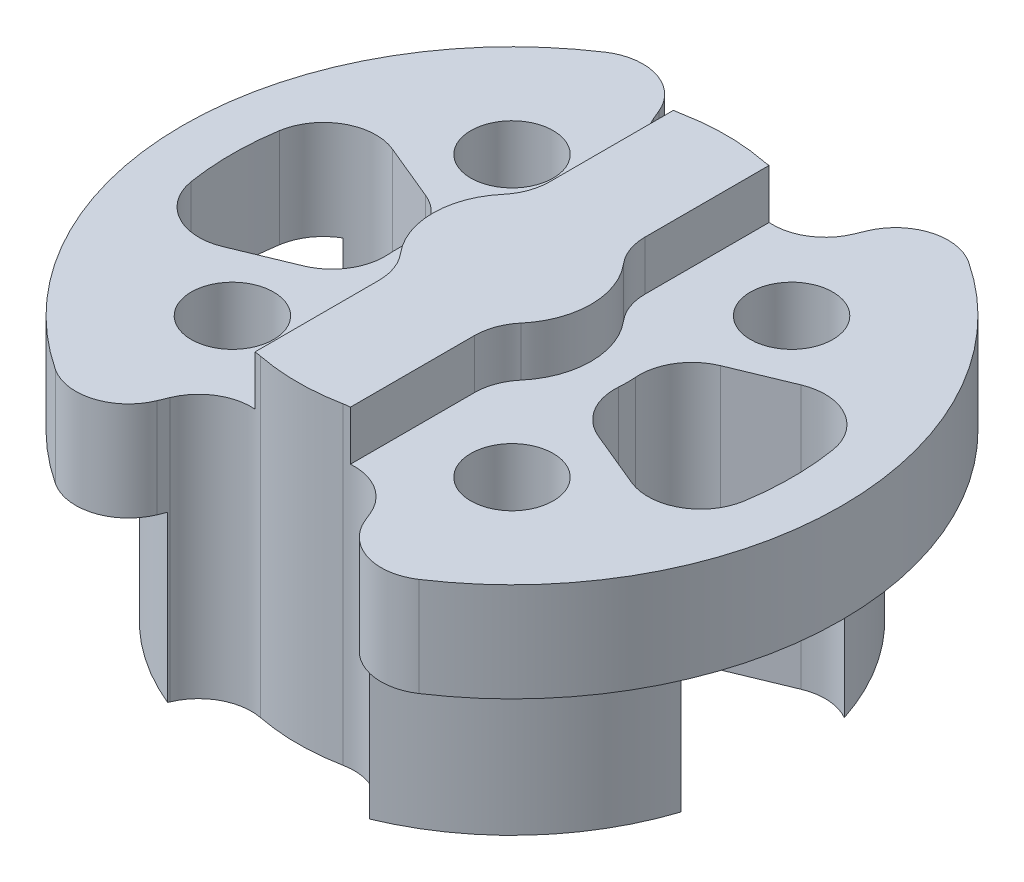
from build123d import *

# Parameters (mm, degrees)
SKETCH1_R                = 10
BOSS_EXTRUDE1_DEPTH      = 8
BOSS_EXTRUDE2_DEPTH      = 1.5
FILLET1_R                = 1.6
SKETCH5_R                = 10
SKETCH5_R_2              = 8
CUT_EXTRUDE1_DEPTH       = 5
CUT_EXTRUDE2_REACH       = 19.037
SKETCH6_R                = 1.2500000000000002
CIRPATTERN1_COUNT        = 4
CUT_EXTRUDE3_DEPTH       = 17.24807680927192
FILLET2_R                = 1.6
CIRPATTERN2_COUNT        = 2
FILLET2_OF_CIRPATTERN2_R = 1.6


with BuildPart() as part:
    # Sketch1 → Boss-Extrude1 (new body)
    with BuildSketch(Plane(origin=(0, 0, 0), x_dir=(1, 0, 0), z_dir=(0, 1, 0))):
        with Locations(Location((0, 0, 0), (0, 0, 270))):
            Circle(SKETCH1_R)
    extrude(amount=BOSS_EXTRUDE1_DEPTH)

    # Sketch4 → Boss-Extrude2 (add)
    with BuildSketch(Plane(origin=(0, 8, 0), x_dir=(1, 0, 0), z_dir=(0, 1, 0))):
        with BuildLine():
            Line((-1.449999999999999, 6.336205489092031), (-1.45, 1.9124591498905275))
            ThreePointArc((-1.45, 1.9124591498905275), (-2.4, 2.9e-16), (-1.45, -1.9124591498905275))
            Line((-1.45, -1.9124591498905275), (-1.449999999999999, -6.336205489092031))
            ThreePointArc((-1.449999999999999, -6.336205489092031), (4e-16, -6.499999999999999), (1.449999999999999, -6.336205489092031))
            Line((1.449999999999999, -6.336205489092031), (1.45, -1.9124591498905275))
            ThreePointArc((1.45, -1.9124591498905275), (2.4, 0), (1.45, 1.9124591498905275))
            Line((1.45, 1.9124591498905275), (1.449999999999999, 6.336205489092031))
            ThreePointArc((1.449999999999999, 6.336205489092031), (4e-16, 6.499999999999999), (-1.449999999999999, 6.336205489092031))
        make_face()
    extrude(amount=BOSS_EXTRUDE2_DEPTH)

    # Fillet1
    fillet1_edges = [part.edges().sort_by_distance(p)[0] for p in [
        (-1.4500000000000002, 8.75, -1.9124591498905277),
        (-1.4500000000000002, 8.75, 1.9124591498905277),
        (1.4500000000000002, 8.75, 1.9124591498905277),
        (1.4500000000000002, 8.75, -1.9124591498905277),
    ]]
    fillet(fillet1_edges, radius=FILLET1_R)

    # Sketch5 → Cut-Extrude1 (cut)
    with BuildSketch(Plane(origin=(0, 0, 0), x_dir=(1, 0, 0), z_dir=(0, 1, 0))):
        with Locations(Location((0, 0, 0), (0, 0, 270))):
            Circle(SKETCH5_R)
        with Locations(Location((0, 0, 0), (0, 0, 90))):
            Circle(SKETCH5_R_2, mode=Mode.SUBTRACT)
    extrude(amount=CUT_EXTRUDE1_DEPTH, mode=Mode.SUBTRACT)

    # Sketch6 → Cut-Extrude2 (cut, up to next)
    with BuildSketch(Plane.XZ, mode=Mode.PRIVATE) as cut_extrude2_sk1:
        with Locations(Location((4.242640687119277, 4.242640687119293, 0), (0, 0, 270))):
            Circle(SKETCH6_R)
    cut_extrude2_tool1 = extrude(cut_extrude2_sk1.sketch, amount=-CUT_EXTRUDE2_REACH, mode=Mode.PRIVATE) & part.part
    cut_extrude2 = cut_extrude2_tool1.solids().sort_by_distance((4.242641, 0, 4.242641))[0]
    add(cut_extrude2, mode=Mode.SUBTRACT)

    # CirPattern1: Cut-Extrude2 ×4 about axis
    cirpattern1_axis = Axis((7.37e-15, 0, -7.37e-15), (0, 1, 0))
    for i in range(1, CIRPATTERN1_COUNT):
        add(cut_extrude2.rotate(cirpattern1_axis, i * 360 / CIRPATTERN1_COUNT), mode=Mode.SUBTRACT)

    # Sketch7 → Cut-Extrude3 (cut, through all)
    with BuildSketch(Plane(origin=(0, 8, 0), x_dir=(1, 0, 0), z_dir=(0, 1, 0))):
        with BuildLine():
            Line((-3.233578363789502, -1.3393920132778183), (-7.852976026345933, -3.2528091751032733))
            ThreePointArc((-7.852976026345933, -3.2528091751032733), (-8.5, -1.04e-15), (-7.852976026345933, 3.2528091751032733))
            Line((-7.852976026345933, 3.2528091751032733), (-3.233578363789502, 1.3393920132778183))
            ThreePointArc((-3.233578363789502, 1.3393920132778183), (-3.5, -4.3e-16), (-3.233578363789502, -1.3393920132778183))
        make_face()
        with BuildLine():
            Line((-2.487442310373089, 6.005216961323361), (-3.826834323650907, 9.238795325112864))
            ThreePointArc((-3.826834323650907, 9.238795325112864), (6.1e-16, 10), (3.826834323650907, 9.238795325112864))
            Line((3.826834323650907, 9.238795325112864), (2.487442310373089, 6.005216961323361))
            ThreePointArc((2.487442310373089, 6.005216961323361), (4e-16, 6.5), (-2.487442310373089, 6.005216961323361))
        make_face()
    cut_extrude3 = extrude(amount=-CUT_EXTRUDE3_DEPTH, mode=Mode.SUBTRACT)

    # Fillet2
    fillet2_edges = [part.edges().sort_by_distance(p)[0] for p in [
        (-7.852976026345933, 6.5, 3.2528091751032733),
        (-7.852976026345933, 6.5, -3.2528091751032733),
        (-3.233578363789502, 4, 1.3393920132778185),
        (-3.233578363789502, 4, -1.3393920132778183),
        (2.487442310373089, 4, -6.005216961323361),
        (-2.4874423103730887, 4, -6.005216961323361),
        (3.826834323650907, 6.5, -9.238795325112866),
        (-3.826834323650907, 6.5, -9.238795325112866),
    ]]
    fillet(fillet2_edges, radius=FILLET2_R)

    # CirPattern2: Cut-Extrude3 ×2 about axis
    cirpattern2_axis = Axis((-8.01e-15, 0, 6.38e-15), (0, 1, 0))
    for i in range(1, CIRPATTERN2_COUNT):
        add(cut_extrude3.rotate(cirpattern2_axis, i * 360 / CIRPATTERN2_COUNT), mode=Mode.SUBTRACT)

    # Fillet2 of CirPattern2
    fillet2_of_cirpattern2_edges = [part.edges().sort_by_distance(p)[0] for p in [
        (7.852976026345917, 6.5, -3.2528091751032595),
        (7.852976026345917, 6.5, 3.252809175103287),
        (3.233578363789486, 4, -1.3393920132778052),
        (3.233578363789486, 4, 1.3393920132778316),
        (-2.487442310373106, 4, 6.005216961323374),
        (2.487442310373072, 4, 6.005216961323374),
        (-3.826834323650924, 6.5, 9.238795325112878),
        (3.8268343236508895, 6.5, 9.238795325112878),
    ]]
    fillet(fillet2_of_cirpattern2_edges, radius=FILLET2_OF_CIRPATTERN2_R)


solid = part.part
